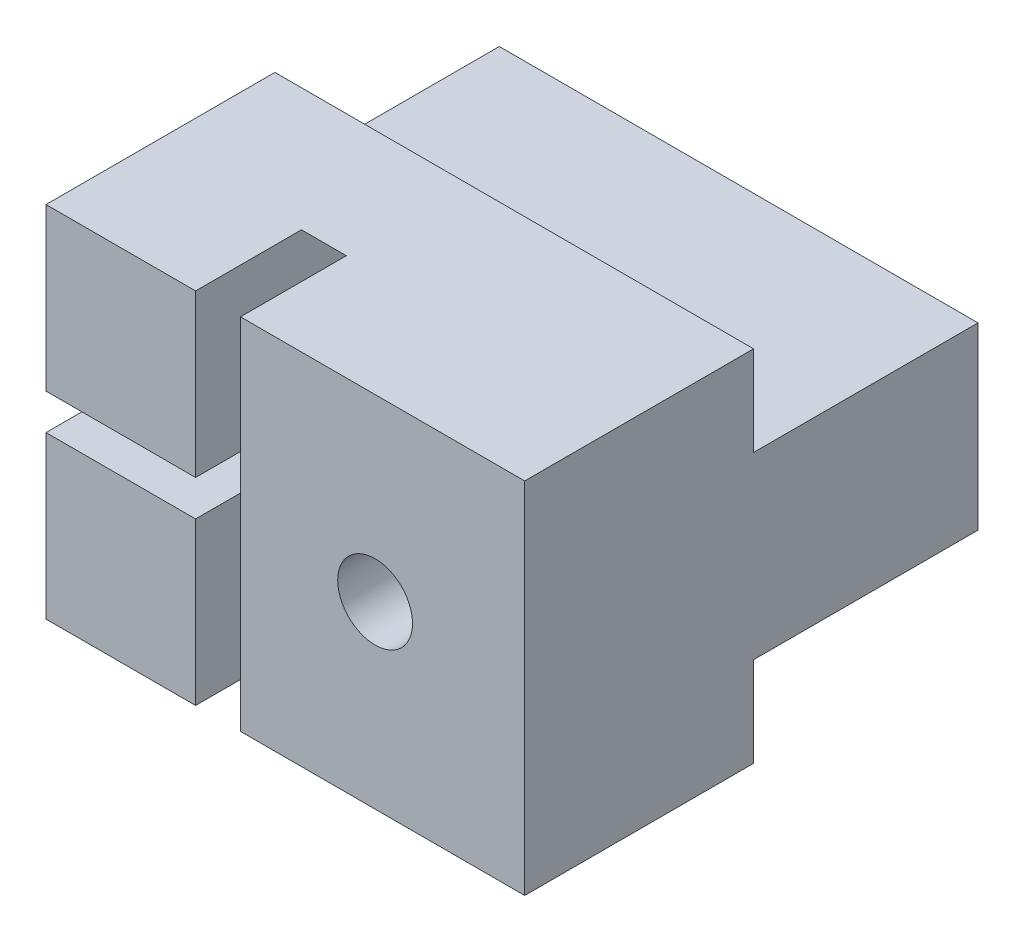
from build123d import *

# Parameters (mm, degrees)
SKETCH_1_W          = 16
SKETCH_1_H          = 12
EXTRUDE_1_DEPTH     = 7.65
SKETCH_2_W          = 5
SKETCH_2_H          = 1.2
CUT_EXTRUDE_1_DEPTH = 4.5
SKETCH_3_R          = 7.15
CUT_EXTRUDE_2_DEPTH = 1.5
SKETCH_4_W          = 16
SKETCH_4_H          = 6
EXTRUDE_2_DEPTH     = 7.5
SKETCH_5_R          = 2.25
CUT_EXTRUDE_3_DEPTH = 7.5
SKETCH_6_R          = 1.25
CUT_EXTRUDE_4_DEPTH = 8.65


with BuildPart() as part:
    # Эскиз1 → Бобышка-Вытянуть1 (new body)
    with BuildSketch(Plane.XY):
        with Locations((-13.599693696, 25)):
            Rectangle(SKETCH_1_W, SKETCH_1_H)
    extrude(amount=EXTRUDE_1_DEPTH)

    # Эскиз2 → Вырез-Вытянуть1 (cut)
    with BuildSketch(Plane.XY.offset(7.65)):
        with Locations((-19.099693696, 25)):
            Rectangle(SKETCH_2_W, SKETCH_2_H)
    extrude(amount=-CUT_EXTRUDE_1_DEPTH, mode=Mode.SUBTRACT)

    # Эскиз3 → Вырез-Вытянуть2 (cut)
    with BuildSketch(Plane.ZY.offset(16.599693696)):
        with Locations((8, 25)):
            Circle(SKETCH_3_R)
    extrude(amount=-CUT_EXTRUDE_2_DEPTH, mode=Mode.SUBTRACT)

    # Эскиз4 → Бобышка-Вытянуть2 (add)
    with BuildSketch(Plane(origin=(0, 0, 0), x_dir=(-1, 0, 0), z_dir=(0, 0, -1))):
        with Locations((13.599693696, 25)):
            Rectangle(SKETCH_4_W, SKETCH_4_H)
    extrude(amount=EXTRUDE_2_DEPTH)

    # Эскиз5 → Вырез-Вытянуть3 (cut)
    with BuildSketch(Plane(origin=(0, 0, -7.5), x_dir=(-1, 0, 0), z_dir=(0, 0, -1))):
        with Locations((10.599693696, 25)):
            Circle(SKETCH_5_R)
    extrude(amount=-CUT_EXTRUDE_3_DEPTH, mode=Mode.SUBTRACT)

    # Эскиз6 → Вырез-Вытянуть4 (cut, through all)
    with BuildSketch(Plane(origin=(0, 0, 0), x_dir=(-1, 0, 0), z_dir=(0, 0, -1))):
        with Locations((10.599693696, 25)):
            Circle(SKETCH_6_R)
    extrude(amount=-CUT_EXTRUDE_4_DEPTH, mode=Mode.SUBTRACT)


solid = part.part
